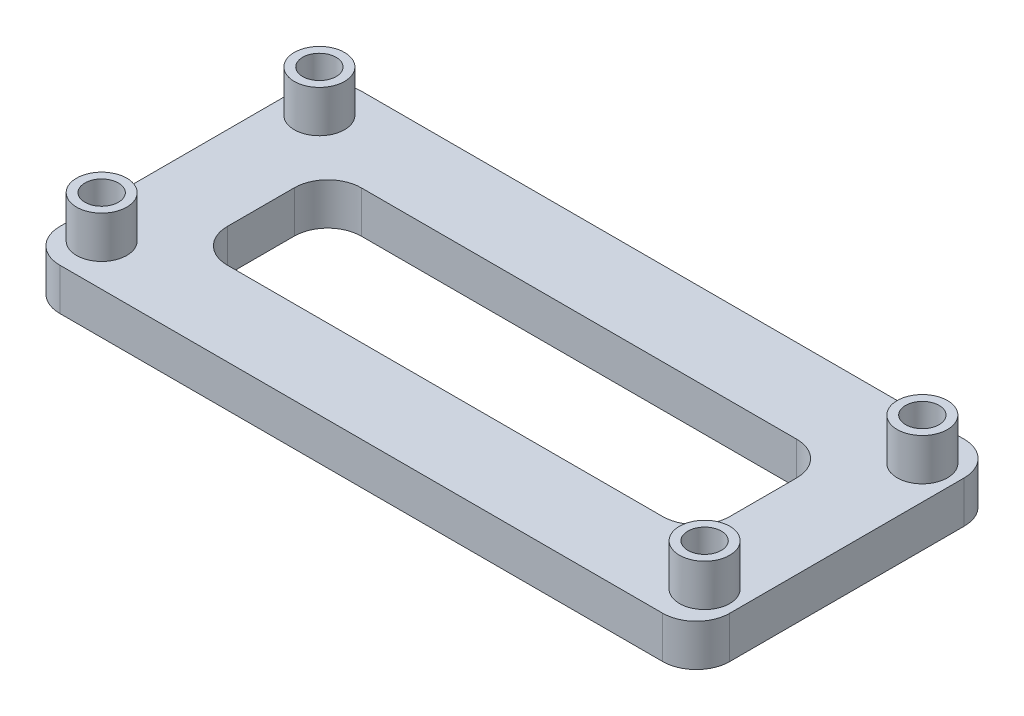
from build123d import *

# Parameters (mm, degrees)
SKETCH1_W           = 50.8
SKETCH1_H           = 22.86
SKETCH1_R           = 1.27
SKETCH1_W_2         = 38.1
SKETCH1_H_2         = 10.16
BOSS_EXTRUDE1_DEPTH = 3.175
SKETCH2_R           = 1.905
SKETCH2_R_2         = 1.27
BOSS_EXTRUDE2_DEPTH = 3.175
FILLET1_R           = 2.54


with BuildPart() as part:
    # Sketch1 → Boss-Extrude1 (new body)
    with BuildSketch(Plane(origin=(0, 0, 0), x_dir=(1, 0, 0), z_dir=(0, 1, 0))):
        with Locations((25.4, 11.43)):
            Rectangle(SKETCH1_W, SKETCH1_H)
        with Locations((2.54, 19.685)):
            Circle(SKETCH1_R, mode=Mode.SUBTRACT)
        with Locations((48.26, 19.685)):
            Circle(SKETCH1_R, mode=Mode.SUBTRACT)
        with Locations((2.54, 3.175)):
            Circle(SKETCH1_R, mode=Mode.SUBTRACT)
        with Locations((48.26, 3.175)):
            Circle(SKETCH1_R, mode=Mode.SUBTRACT)
        with Locations((25.4, 11.43)):
            Rectangle(SKETCH1_W_2, SKETCH1_H_2, mode=Mode.SUBTRACT)
    extrude(amount=BOSS_EXTRUDE1_DEPTH)

    # Sketch2 → Boss-Extrude2 (add)
    with BuildSketch(Plane(origin=(0, 3.175, 0), x_dir=(1, 0, 0), z_dir=(0, 1, 0))):
        with Locations((2.54, 19.685)):
            Circle(SKETCH2_R)
        with Locations((2.54, 19.685)):
            Circle(SKETCH2_R_2, mode=Mode.SUBTRACT)
        with Locations((2.54, 3.175)):
            Circle(SKETCH2_R)
        with Locations((2.54, 3.175)):
            Circle(SKETCH2_R_2, mode=Mode.SUBTRACT)
        with Locations((48.26, 3.175)):
            Circle(SKETCH2_R)
        with Locations((48.26, 3.175)):
            Circle(SKETCH2_R_2, mode=Mode.SUBTRACT)
        with Locations((48.26, 19.685)):
            Circle(SKETCH2_R)
        with Locations((48.26, 19.685)):
            Circle(SKETCH2_R_2, mode=Mode.SUBTRACT)
    extrude(amount=BOSS_EXTRUDE2_DEPTH)

    # Fillet1
    fillet1_edges = [part.edges().sort_by_distance(p)[0] for p in [
        (6.35, 1.5875, -16.51),
        (6.35, 1.5875, -6.35),
        (44.45, 1.5875, -6.35),
        (44.45, 1.5875, -16.51),
        (0, 1.5875, -22.86),
        (50.8, 1.5875, -22.86),
        (50.8, 1.5875, 0),
        (0, 1.5875, 0),
    ]]
    fillet(fillet1_edges, radius=FILLET1_R)


solid = part.part
